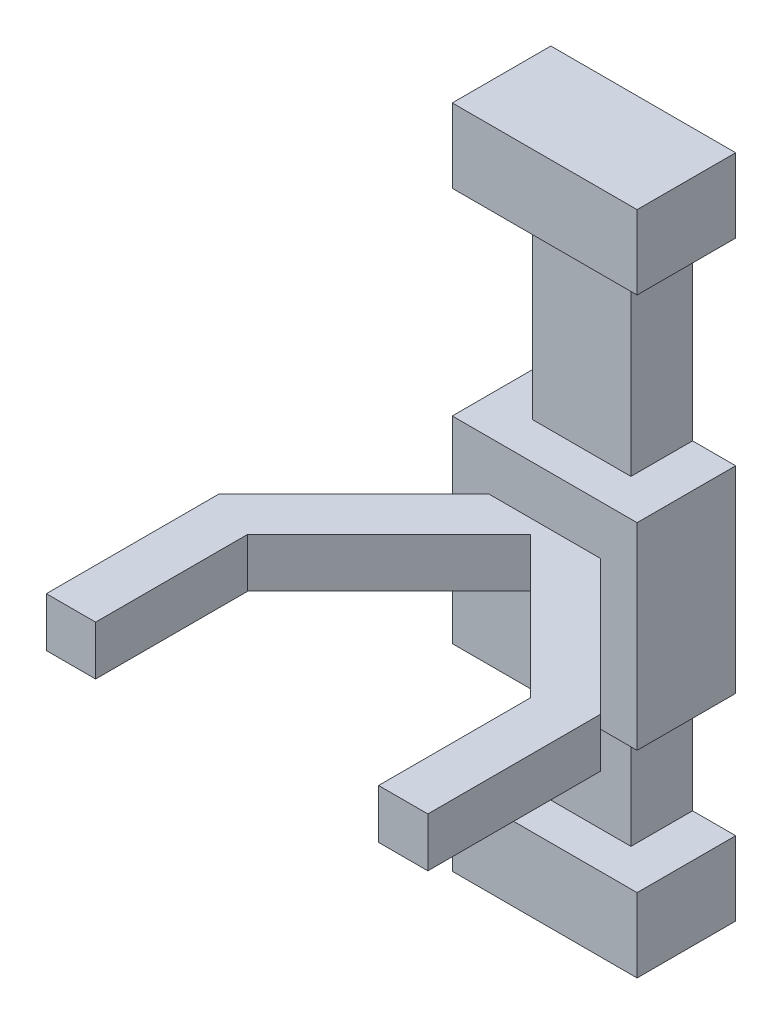
from build123d import *

# Parameters (mm, degrees)
SKETCH1_W           = 40
SKETCH1_H           = 210
BOSS_EXTRUDE1_DEPTH = 25
SKETCH2_W           = 40
SKETCH2_H           = 25
BOSS_EXTRUDE2_DEPTH = 30
SKETCH3_W           = 40
SKETCH3_H           = 25
BOSS_EXTRUDE3_DEPTH = 30
BOSS_EXTRUDE4_DEPTH = 80
SKETCH6_W           = 20
SKETCH6_H           = 20
BOSS_EXTRUDE5_DEPTH = 120
SKETCH7_W           = 20
SKETCH7_H           = 20
BOSS_EXTRUDE6_DEPTH = 120
SKETCH8_W           = 20
SKETCH8_H           = 20
BOSS_EXTRUDE7_DEPTH = 70


with BuildPart() as part:
    # Sketch1 → Boss-Extrude1 (new body)
    with BuildSketch(Plane.XY):
        with Locations((20, 105)):
            Rectangle(SKETCH1_W, SKETCH1_H)
    extrude(amount=BOSS_EXTRUDE1_DEPTH)

    # Sketch2 → Boss-Extrude2 (add)
    with BuildSketch(Plane(origin=(0, 210, 0), x_dir=(1, 0, 0), z_dir=(0, 1, 0))):
        Polygon((0, 0), (-17.5, 0), (-17.5, -40), (57.5, -40), (57.5, 0), (40, 0), (40, -25), (0, -25), align=None)
        with Locations((20, -12.5)):
            Rectangle(SKETCH2_W, SKETCH2_H)
    extrude(amount=BOSS_EXTRUDE2_DEPTH)

    # Sketch3 → Boss-Extrude3 (add)
    with BuildSketch(Plane.XZ):
        Polygon((57.5, 40), (57.5, 0), (40, 0), (40, 25), (0, 25), (0, 0), (-17.5, 0), (-17.5, 40), align=None)
        with Locations((20, 12.5)):
            Rectangle(SKETCH3_W, SKETCH3_H)
    extrude(amount=BOSS_EXTRUDE3_DEPTH)

    # Sketch5 → Boss-Extrude4 (add)
    with BuildSketch(Plane(origin=(0, 50, 0), x_dir=(1, 0, 0), z_dir=(0, 1, 0))):
        Polygon((57.5, 0), (0, 0), (-17.5, 0), (-17.5, -40), (57.5, -40), align=None)
    extrude(amount=BOSS_EXTRUDE4_DEPTH)

    # Sketch6 → Boss-Extrude5 (add)
    with BuildSketch(Plane(origin=(11.25, 0, 11.25), x_dir=(0.707106781, 0, -0.707106781), z_dir=(0.707106781, 0, 0.707106781))):
        with Locations((-8.158639918, 100)):
            Rectangle(SKETCH6_W, SKETCH6_H)
    extrude(amount=BOSS_EXTRUDE5_DEPTH)

    # Sketch7 → Boss-Extrude6 (add)
    with BuildSketch(Plane(origin=(8.75, 0, -8.75), x_dir=(0.707106781, 0, 0.707106781), z_dir=(-0.707106781, 0, 0.707106781))):
        with Locations((36.442911166, 100)):
            Rectangle(SKETCH7_W, SKETCH7_H)
    extrude(amount=BOSS_EXTRUDE6_DEPTH)

    # Sketch8 → Boss-Extrude7 (add)
    with BuildSketch(Plane.XY.offset(94.800775542)):
        with Locations((-47.404851943, 100)):
            Rectangle(SKETCH8_W, SKETCH8_H)
        with Locations((87.404851943, 100)):
            Rectangle(SKETCH8_W, SKETCH8_H)
    extrude(amount=BOSS_EXTRUDE7_DEPTH)


solid = part.part
